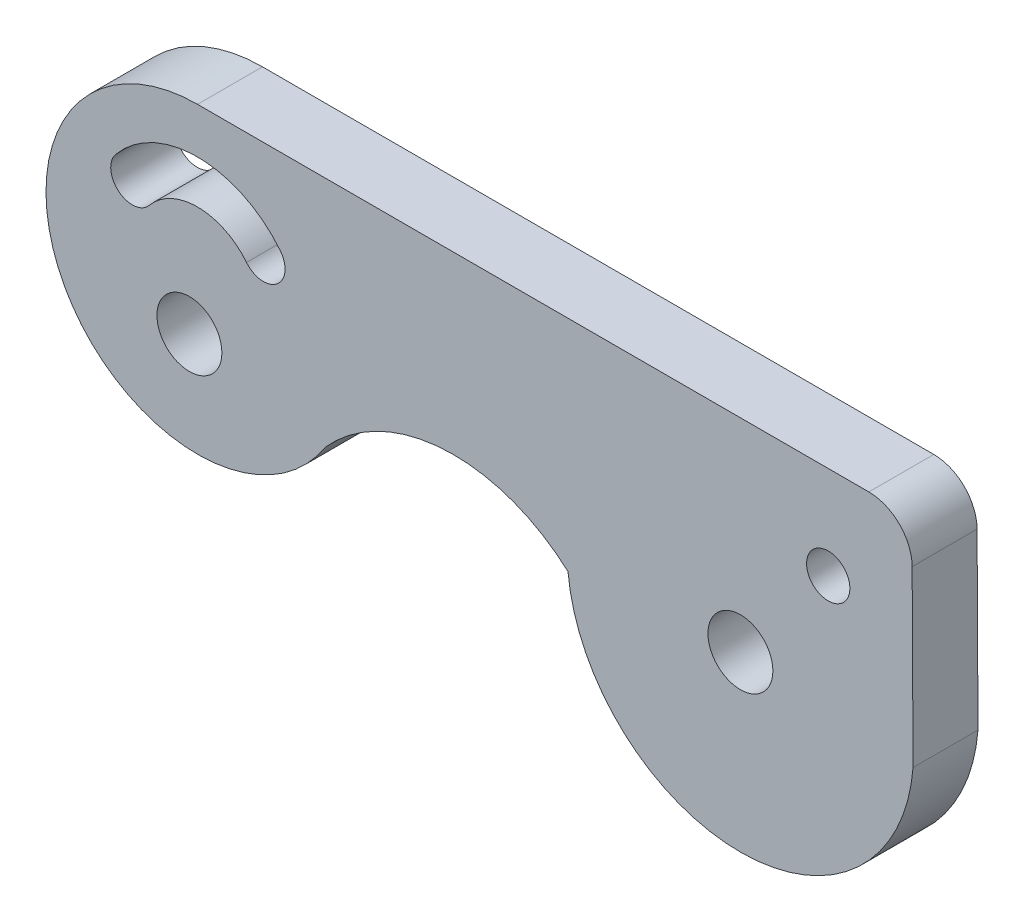
from build123d import *

# Parameters (mm, degrees)
SKETCH1_R           = 1.5
SKETCH1_R_2         = 1
BOSS_EXTRUDE1_DEPTH = 3


with BuildPart() as part:
    # Sketch1 → Boss-Extrude1 (new body)
    with BuildSketch(Plane.XY):
        with BuildLine():
            Line((0, 0), (31.010482732, 0))
            ThreePointArc((31.010482732, 0), (32.420975481, -0.582075389), (33.010455116, -1.989489797))
            Line((33.010455116, -1.989489797), (33.052571579, -10.003774465))
            ThreePointArc((33.052571579, -10.003774465), (25.143173524, -17.377139631), (17.113116724, -10.13536642))
            ThreePointArc((17.113116724, -10.13536642), (11.370616348, -8.112797173), (5.895074629, -10.774664902))
            ThreePointArc((5.895074629, -10.774664902), (-6.140954906, -10.359862027), (0, 0))
        make_face()
        with Locations((25.077129875, -9.377412246)):
            Circle(SKETCH1_R, mode=Mode.SUBTRACT)
        with Locations((29.13412022, -4.298945023)):
            Circle(SKETCH1_R_2, mode=Mode.SUBTRACT)
        with Locations((-0.375746772, -9.377412246)):
            Circle(SKETCH1_R, mode=Mode.SUBTRACT)
        with BuildLine():
            ThreePointArc((2.262283142, -5.193372604), (0.019600772, -4.104927744), (-2.237613726, -5.162906542))
            ThreePointArc((-2.237613726, -5.162906542), (-3.645044504, -5.301248889), (-3.783386851, -3.893818111))
            ThreePointArc((-3.783386851, -3.893818111), (0.033141244, -2.10497358), (3.825098224, -3.945330531))
            ThreePointArc((3.825098224, -3.945330531), (3.66771172, -5.350759109), (2.262283142, -5.193372604))
        make_face(mode=Mode.SUBTRACT)
    extrude(amount=BOSS_EXTRUDE1_DEPTH)


solid = part.part
